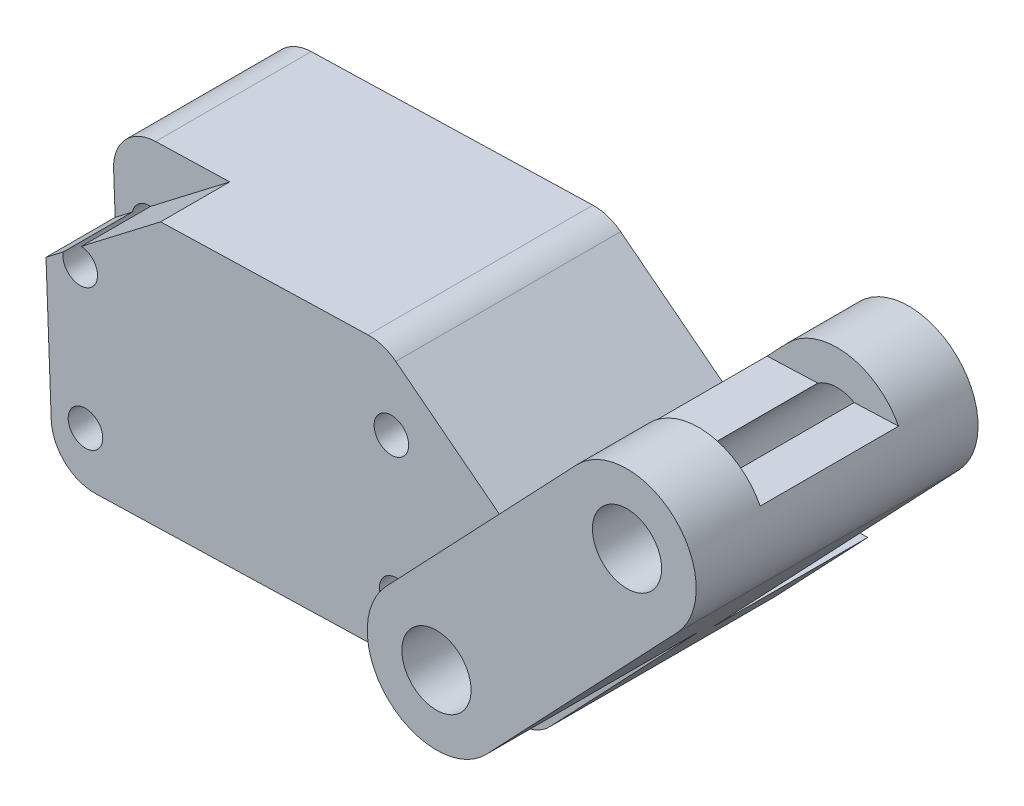
from build123d import *

# Parameters (mm, degrees)
SKETCH1_R           = 1
BOSS_EXTRUDE1_DEPTH = 9
SKETCH2_R           = 2
SKETCH2_R_2         = 1
BOSS_EXTRUDE3_DEPTH = 4
SKETCH3_R           = 2
BOSS_EXTRUDE4_DEPTH = 12.3
SKETCH4_W           = 8
SKETCH4_H           = 2.3
CUT_EXTRUDE1_DEPTH  = 100


with BuildPart() as part:
    # Sketch1 → Boss-Extrude1 (new body)
    with BuildSketch(Plane.XY):
        with BuildLine():
            Line((37.44618629, 199.100176708), (21.157913115, 198.645068222))
            ThreePointArc((21.157913115, 198.645068222), (19.402812913, 197.854741355), (18.729526359, 196.051500247))
            Line((18.729526359, 196.051500247), (19.122128495, 185.677380061))
            ThreePointArc((19.122128495, 185.677380061), (19.911642331, 183.946998209), (21.690165088, 183.272898624))
            Line((21.690165088, 183.272898624), (46.213174666, 183.958092791))
            ThreePointArc((46.213174666, 183.958092791), (47.16140114, 184.173792868), (47.955590742, 184.734972736))
            Line((47.955590742, 184.734972736), (53.340647935, 190.401756173))
            Line((53.340647935, 190.401756173), (50.421306908, 190.401756173))
            ThreePointArc((50.421306908, 190.401756173), (49.61024665, 190.536976848), (48.886924084, 190.928011166))
            Line((48.886924084, 190.928011166), (39.050394032, 198.574897009))
            ThreePointArc((39.050394032, 198.574897009), (38.293965035, 198.977028229), (37.44618629, 199.100176708))
        make_face()
        with Locations((20.799047924, 194.252293006)):
            Circle(SKETCH1_R, mode=Mode.SUBTRACT)
        with Locations((38.792906294, 194.755057023)):
            Circle(SKETCH1_R, mode=Mode.SUBTRACT)
        with Locations((39.095459561, 186.760388464)):
            Circle(SKETCH1_R, mode=Mode.SUBTRACT)
        with Locations((21.101601191, 186.257624448)):
            Circle(SKETCH1_R, mode=Mode.SUBTRACT)
    extrude(amount=BOSS_EXTRUDE1_DEPTH)

    # Sketch2 → Boss-Extrude3 (add)
    with BuildSketch(Plane.XY.offset(9)):
        with BuildLine():
            Line((61.820501213, 210.938669532), (45.388864845, 193.647390819))
            Line((45.388864845, 193.647390819), (48.886924084, 190.928011166))
            ThreePointArc((48.886924084, 190.928011166), (49.61024665, 190.536976848), (50.421306908, 190.401756173))
            Line((50.421306908, 190.401756173), (53.340647935, 190.401756173))
            Line((53.340647935, 190.401756173), (67.619672397, 205.427806299))
            ThreePointArc((67.619672397, 205.427806299), (67.475518422, 211.082823507), (61.820501213, 210.938669532))
        make_face()
        with Locations((53.698360337, 196.584895548)):
            Circle(SKETCH2_R, mode=Mode.SUBTRACT)
        with Locations((64.720086805, 208.183237915)):
            Circle(SKETCH2_R, mode=Mode.SUBTRACT)
        with BuildLine():
            Line((37.44618629, 199.100176708), (25.44618629, 198.764886296))
            Line((25.44618629, 198.764886296), (20.867726047, 195.249931876))
            ThreePointArc((20.867726047, 195.249931876), (21.530032918, 194.934686542), (21.799047924, 194.252293006))
            ThreePointArc((21.799047924, 194.252293006), (20.702907489, 193.256925226), (19.817533891, 194.443683189))
            Line((19.817533891, 194.443683189), (18.819373463, 193.677380061))
            Line((18.819373463, 193.677380061), (19.122128495, 185.677380061))
            ThreePointArc((19.122128495, 185.677380061), (19.911642331, 183.946998209), (21.690165088, 183.272898624))
            Line((21.690165088, 183.272898624), (46.213174666, 183.958092791))
            ThreePointArc((46.213174666, 183.958092791), (47.16140114, 184.173792868), (47.955590742, 184.734972736))
            Line((47.955590742, 184.734972736), (53.340647935, 190.401756173))
            Line((53.340647935, 190.401756173), (50.421306908, 190.401756173))
            ThreePointArc((50.421306908, 190.401756173), (49.61024665, 190.536976848), (48.886924084, 190.928011166))
            Line((48.886924084, 190.928011166), (45.388864845, 193.647390819))
            Line((45.388864845, 193.647390819), (39.050394032, 198.574897009))
            ThreePointArc((39.050394032, 198.574897009), (38.293965035, 198.977028229), (37.44618629, 199.100176708))
        make_face()
        with Locations((21.101601191, 186.257624448)):
            Circle(SKETCH2_R_2, mode=Mode.SUBTRACT)
        with Locations((39.095459561, 186.760388464)):
            Circle(SKETCH2_R_2, mode=Mode.SUBTRACT)
        with Locations((38.792906294, 194.755057023)):
            Circle(SKETCH2_R_2, mode=Mode.SUBTRACT)
    extrude(amount=BOSS_EXTRUDE3_DEPTH)

    # Sketch3 → Boss-Extrude4 (add)
    with BuildSketch(Plane.XY.offset(13)):
        with BuildLine():
            Line((67.619672397, 205.427806299), (56.597945929, 193.829463931))
            ThreePointArc((56.597945929, 193.829463931), (50.94292872, 193.685309956), (50.798774745, 199.340327165))
            Line((50.798774745, 199.340327165), (61.820501213, 210.938669532))
            ThreePointArc((61.820501213, 210.938669532), (67.475518422, 211.082823507), (67.619672397, 205.427806299))
        make_face()
        with Locations((64.720086805, 208.183237915)):
            Circle(SKETCH3_R, mode=Mode.SUBTRACT)
        with Locations((53.698360337, 196.584895548)):
            Circle(SKETCH3_R, mode=Mode.SUBTRACT)
    extrude(amount=BOSS_EXTRUDE4_DEPTH)

    # Sketch4 → Cut-Extrude1 (cut)
    with BuildSketch(Plane(origin=(26.111576718, 0.988176406, 0), x_dir=(0, 0, 1), z_dir=(-0.99928467, -0.037817308, 0))):
        with Locations((17.15, 208.436778709)):
            Rectangle(SKETCH4_W, SKETCH4_H)
    extrude(amount=-CUT_EXTRUDE1_DEPTH, mode=Mode.SUBTRACT)


solid = part.part
